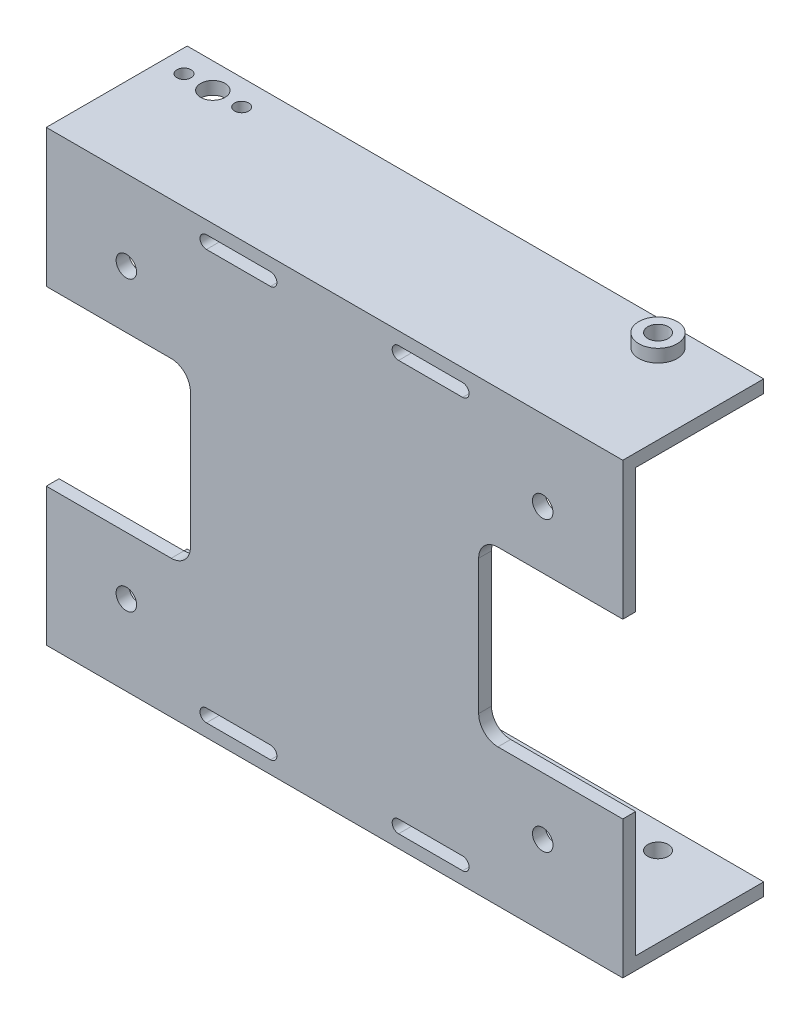
from build123d import *

# Parameters (mm, degrees)
SKETCH_1_W                = 90
SKETCH_1_H                = 70
SKETCH_1_W_2              = 86
SKETCH_1_H_2              = 66
EXTRUDE_1_DEPTH           = 22
SKETCH_2_W                = 90
SKETCH_2_H                = 70
EXTRUDE_2_DEPTH           = 2
CUT_EXTRUDE_1_DEPTH       = 1
CUT_EXTRUDE_1_DEPTH_BACK  = 91
SKETCH_4_R                = 1.5
CUT_EXTRUDE_2_DEPTH       = 1
CUT_EXTRUDE_2_DEPTH_BACK  = 91
CUT_EXTRUDE_3_DEPTH       = 21
CUT_EXTRUDE_3_DEPTH_BACK  = 3
SKETCH_7_R                = 1.9
SKETCH_7_R_2              = 1.6
CUT_EXTRUDE_4_DEPTH       = 1
CUT_EXTRUDE_4_DEPTH_BACK  = 71
SKETCH_9_R                = 1.1
CUT_EXTRUDE_5_DEPTH       = 1
CUT_EXTRUDE_5_DEPTH_BACK  = 71
SKETCH_10_R               = 3
SKETCH_10_R_2             = 1.6
EXTRUDE_3_DEPTH           = 2
SKETCH_11_R               = 3
SKETCH_11_R_2             = 1.6
EXTRUDE_4_DEPTH           = 2
SKETCH_12_R               = 1.6
CUT_EXTRUDE_6_DEPTH       = 1
CUT_EXTRUDE_6_DEPTH_BACK  = 23
SKETCH_16_W               = 11
SKETCH_16_H               = 27
CUT_EXTRUDE_9_DEPTH       = 1
CUT_EXTRUDE_9_DEPTH_BACK  = 91
SKETCH_17_W               = 45
SKETCH_17_H               = 27
EXTRUDE_6_DEPTH           = 2
FILLET_1_R                = 3
CUT_EXTRUDE_10_DEPTH      = 89
CUT_EXTRUDE_10_DEPTH_BACK = 3


with BuildPart() as part:
    # Эскиз1 → Бобышка-Вытянуть1 (new body)
    with BuildSketch(Plane.XY):
        Rectangle(SKETCH_1_W, SKETCH_1_H)
        Rectangle(SKETCH_1_W_2, SKETCH_1_H_2, mode=Mode.SUBTRACT)
    extrude(amount=EXTRUDE_1_DEPTH)

    # Эскиз2 → Бобышка-Вытянуть2 (add)
    with BuildSketch(Plane.XY.offset(22)):
        Rectangle(SKETCH_2_W, SKETCH_2_H)
    extrude(amount=-EXTRUDE_2_DEPTH)

    # Эскиз3 → Вырез-Вытянуть1 (cut, two sides)
    with BuildSketch(Plane.ZY.offset(45)) as cut_extrude_1_sk:
        with BuildLine():
            Line((17, 7.5), (17, -7.5))
            ThreePointArc((17, -7.5), (11, -13.5), (5, -7.5))
            Line((5, -7.5), (5, 7.5))
            ThreePointArc((5, 7.5), (11, 13.5), (17, 7.5))
        make_face()
    extrude(amount=CUT_EXTRUDE_1_DEPTH, mode=Mode.SUBTRACT)
    extrude(cut_extrude_1_sk.sketch, amount=-CUT_EXTRUDE_1_DEPTH_BACK, mode=Mode.SUBTRACT)

    # Эскиз4 → Вырез-Вытянуть2 (cut, two sides)
    with BuildSketch(Plane.ZY.offset(45)) as cut_extrude_2_sk:
        with Locations((11, 26)):
            Circle(SKETCH_4_R)
        with Locations((11, -26)):
            Circle(SKETCH_4_R)
    extrude(amount=CUT_EXTRUDE_2_DEPTH, mode=Mode.SUBTRACT)
    extrude(cut_extrude_2_sk.sketch, amount=-CUT_EXTRUDE_2_DEPTH_BACK, mode=Mode.SUBTRACT)

    # Эскиз5 → Вырез-Вытянуть3 (cut, two sides)
    with BuildSketch(Plane(origin=(0, 0, 20), x_dir=(-1, 0, 0), z_dir=(0, 0, -1))) as cut_extrude_3_sk:
        with BuildLine():
            Line((-10, 31), (-20, 31))
            ThreePointArc((-20, 31), (-21, 32), (-20, 33))
            Line((-20, 33), (-10, 33))
            ThreePointArc((-10, 33), (-9, 32), (-10, 31))
        make_face()
        with BuildLine():
            Line((10, 33), (20, 33))
            ThreePointArc((20, 33), (21, 32), (20, 31))
            Line((20, 31), (10, 31))
            ThreePointArc((10, 31), (9, 32), (10, 33))
        make_face()
        with BuildLine():
            Line((10, -31), (20, -31))
            ThreePointArc((20, -31), (21, -32), (20, -33))
            Line((20, -33), (10, -33))
            ThreePointArc((10, -33), (9, -32), (10, -31))
        make_face()
        with BuildLine():
            Line((-10, -33), (-20, -33))
            ThreePointArc((-20, -33), (-21, -32), (-20, -31))
            Line((-20, -31), (-10, -31))
            ThreePointArc((-10, -31), (-9, -32), (-10, -33))
        make_face()
    extrude(amount=CUT_EXTRUDE_3_DEPTH, mode=Mode.SUBTRACT)
    extrude(cut_extrude_3_sk.sketch, amount=-CUT_EXTRUDE_3_DEPTH_BACK, mode=Mode.SUBTRACT)

    # Эскиз7 → Вырез-Вытянуть4 (cut, two sides)
    with BuildSketch(Plane(origin=(0, 35, 0), x_dir=(1, 0, 0), z_dir=(0, 1, 0))) as cut_extrude_4_sk:
        with Locations((-37, -4)):
            Circle(SKETCH_7_R)
        with Locations((32.5, -4)):
            Circle(SKETCH_7_R_2)
    extrude(amount=CUT_EXTRUDE_4_DEPTH, mode=Mode.SUBTRACT)
    extrude(cut_extrude_4_sk.sketch, amount=-CUT_EXTRUDE_4_DEPTH_BACK, mode=Mode.SUBTRACT)

    # Эскиз9 → Вырез-Вытянуть5 (cut, two sides)
    with BuildSketch(Plane(origin=(0, 35, 0), x_dir=(1, 0, 0), z_dir=(0, 1, 0))) as cut_extrude_5_sk:
        with Locations((-32.5, -4)):
            Circle(SKETCH_9_R)
        with Locations((-41.5, -4)):
            Circle(SKETCH_9_R)
    extrude(amount=CUT_EXTRUDE_5_DEPTH, mode=Mode.SUBTRACT)
    extrude(cut_extrude_5_sk.sketch, amount=-CUT_EXTRUDE_5_DEPTH_BACK, mode=Mode.SUBTRACT)

    # Эскиз10 → Бобышка-Вытянуть3 (add)
    with BuildSketch(Plane(origin=(0, 35, 0), x_dir=(1, 0, 0), z_dir=(0, 1, 0))):
        with Locations((32.5, -4)):
            Circle(SKETCH_10_R)
        with Locations((32.5, -4)):
            Circle(SKETCH_10_R_2, mode=Mode.SUBTRACT)
    extrude(amount=EXTRUDE_3_DEPTH)

    # Эскиз11 → Бобышка-Вытянуть4 (add)
    with BuildSketch(Plane.XZ.offset(35)):
        with Locations((32.5, 4)):
            Circle(SKETCH_11_R)
        with Locations((32.5, 4)):
            Circle(SKETCH_11_R_2, mode=Mode.SUBTRACT)
    extrude(amount=EXTRUDE_4_DEPTH)

    # Эскиз12 → Вырез-Вытянуть6 (cut, two sides)
    with BuildSketch(Plane.XY.offset(22)) as cut_extrude_6_sk:
        with Locations((-32.5, 22.5)):
            Circle(SKETCH_12_R)
        with Locations((-32.5, -22.5)):
            Circle(SKETCH_12_R)
        with Locations((32.5, -22.5)):
            Circle(SKETCH_12_R)
        with Locations((32.5, 22.5)):
            Circle(SKETCH_12_R)
    extrude(amount=CUT_EXTRUDE_6_DEPTH, mode=Mode.SUBTRACT)
    extrude(cut_extrude_6_sk.sketch, amount=-CUT_EXTRUDE_6_DEPTH_BACK, mode=Mode.SUBTRACT)

    # Эскиз16 → Вырез-Вытянуть9 (cut, two sides)
    with BuildSketch(Plane(origin=(45, 0, 0), x_dir=(0, 0, -1), z_dir=(1, 0, 0))) as cut_extrude_9_sk:
        with Locations((-16.5, 0)):
            Rectangle(SKETCH_16_W, SKETCH_16_H)
    extrude(amount=CUT_EXTRUDE_9_DEPTH, mode=Mode.SUBTRACT)
    extrude(cut_extrude_9_sk.sketch, amount=-CUT_EXTRUDE_9_DEPTH_BACK, mode=Mode.SUBTRACT)

    # Эскиз17 → Бобышка-Вытянуть6 (add)
    with BuildSketch(Plane.XY.offset(22)):
        Rectangle(SKETCH_17_W, SKETCH_17_H)
    extrude(amount=-EXTRUDE_6_DEPTH)

    # Скругление1
    fillet_1_edges = [part.edges().sort_by_distance(p)[0] for p in [
        (-22.5, -13.5, 21),
        (-22.5, 13.5, 21),
        (22.5, 13.5, 21),
        (22.5, -13.5, 21),
    ]]
    fillet(fillet_1_edges, radius=FILLET_1_R)

    # Эскиз18 → Вырез-Вытянуть10 (cut, two sides)
    with BuildSketch(Plane.ZY.offset(-43)) as cut_extrude_10_sk:
        with BuildLine():
            Line((11, 13.5), (20, 13.5))
            Line((20, 13.5), (20, 33))
            Line((20, 33), (0, 33))
            Line((0, 33), (0, -33))
            Line((0, -33), (20, -33))
            Line((20, -33), (20, -13.5))
            Line((20, -13.5), (11, -13.5))
            ThreePointArc((11, -13.5), (6.757359313, -11.742640687), (5, -7.5))
            Line((5, -7.5), (5, 7.5))
            ThreePointArc((5, 7.5), (6.757359313, 11.742640687), (11, 13.5))
        make_face()
    extrude(amount=CUT_EXTRUDE_10_DEPTH, mode=Mode.SUBTRACT)
    extrude(cut_extrude_10_sk.sketch, amount=-CUT_EXTRUDE_10_DEPTH_BACK, mode=Mode.SUBTRACT)


solid = part.part
